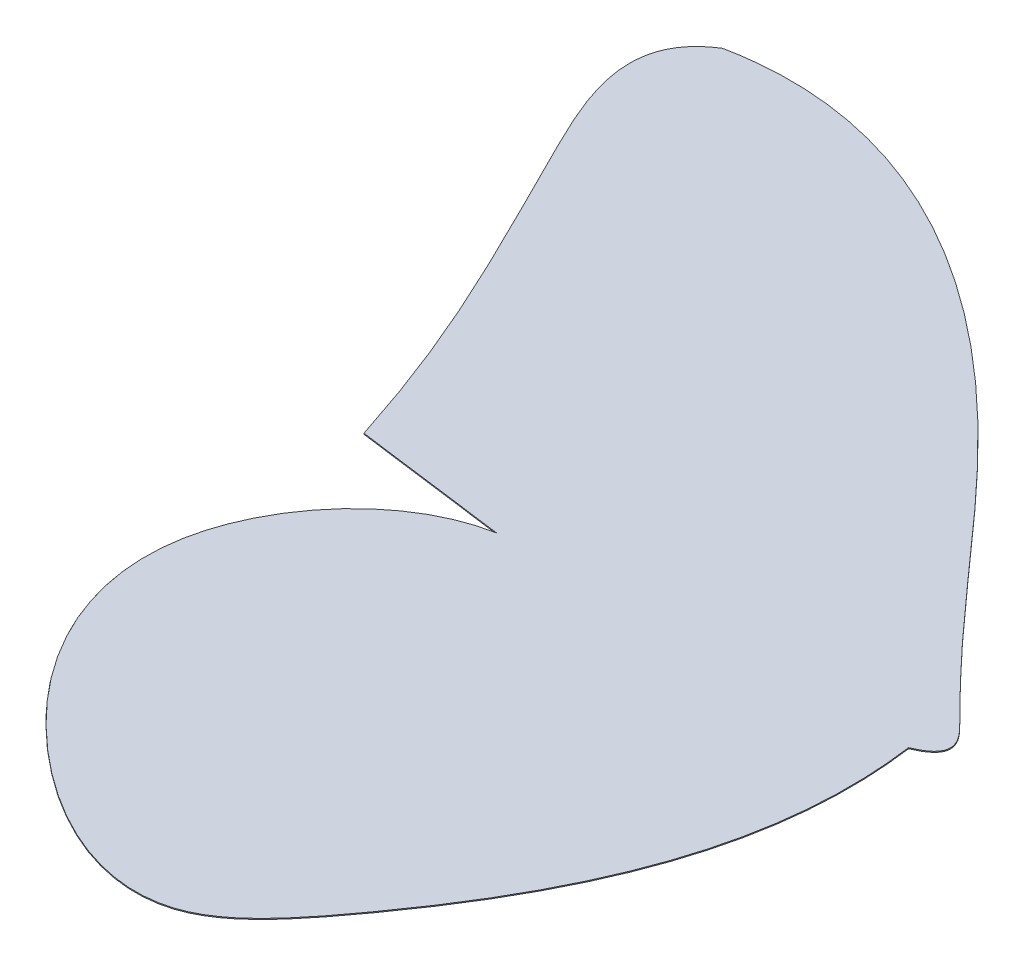
from build123d import *

# Parameters (mm, degrees)
SKETCH2_W           = 2743.2
SKETCH2_H           = 2743.2
BOSS_EXTRUDE5_DEPTH = 2.54
SKETCH9_OUTSIDE_W   = 3521.094
SKETCH9_OUTSIDE_H   = 3521.094
CUT_EXTRUDE2_DEPTH  = 3880.471475807


with BuildPart() as part:
    # Sketch2 → Boss-Extrude5 (new body)
    with BuildSketch(Plane(origin=(0, 0, 0), x_dir=(1, 0, 0), z_dir=(0, 1, 0))):
        with Locations((1371.6, -1371.6)):
            Rectangle(SKETCH2_W, SKETCH2_H)
    extrude(amount=BOSS_EXTRUDE5_DEPTH)

    # Sketch9 outside → Cut-Extrude2 (cut, through all)
    with BuildSketch(Plane(origin=(0, 2.54, 0), x_dir=(1, 0, 0), z_dir=(0, 1, 0))):
        with Locations((1371.6, -1371.6)):
            Rectangle(SKETCH9_OUTSIDE_W, SKETCH9_OUTSIDE_H)
        with BuildLine():
            add(Edge.make_bspline(
                [(912.585058107, -1380.707439323), (799.362573134, -1030.842063307), (626.216783252, -707.789047244), (347.730227543, -136.113323122), (508.214752154, -36.449395209)],
                knots=[0, 0, 0, 0, 0.664398964, 1, 1, 1, 1], degree=3))
            add(Edge.make_bspline(
                [(508.214752154, -36.449395209), (955.383274648, 54.969929974), (1690.708013053, -467.116998919), (2118.573820237, -1036.085136387), (2437.402462422, -1339.935496878), (2340.631543996, -1380.707439323)],
                knots=[0, 0, 0, 0, 0.546040292, 0.928933193, 1, 1, 1, 1], degree=3))
            add(Edge.make_bspline(
                [(1313.118260063, -1433.203608617), (1106.802397652, -1470.758729373), (761.274563988, -1890.418719789), (1112.637774022, -2520.959291735), (1714.429777895, -2829.484887067), (2197.494405804, -2240.026987128), (2397.362199196, -1797.202060136), (2340.631543996, -1380.707439323)],
                knots=[0, 0, 0, 0, 0.180767114, 0.388096448, 0.561369391, 0.651443692, 1, 1, 1, 1], degree=3))
            Line((1313.118260063, -1433.203608617), (912.585058107, -1380.707439323))
        make_face(mode=Mode.SUBTRACT)
    extrude(amount=-CUT_EXTRUDE2_DEPTH, mode=Mode.SUBTRACT)


solid = part.part
